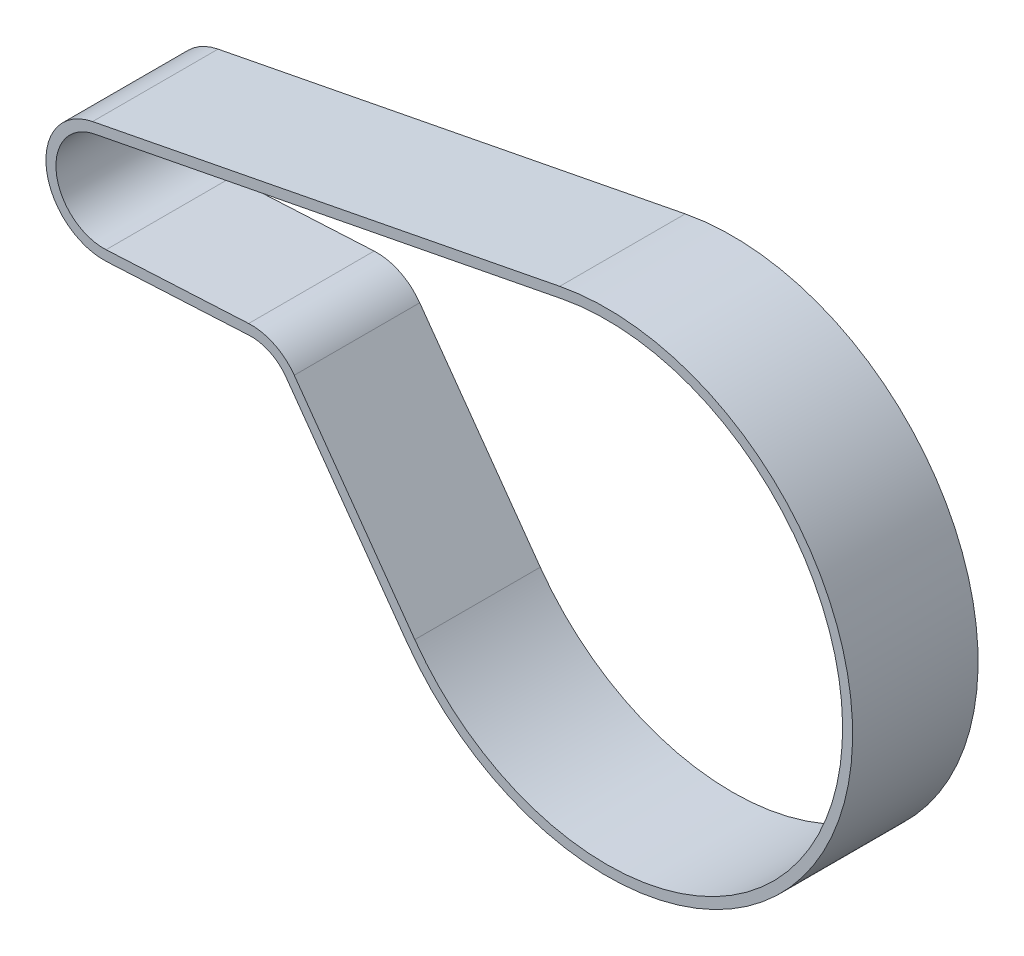
from build123d import *

# Parameters (mm, degrees)
EXTRUDE_THIN1_DEPTH      = 15.5
EXTRUDE_THIN1_DEPTH_BACK = 9.5


with BuildPart() as part:
    # Sketch2 → Extrude-Thin1 (new, two sides)
    with BuildSketch(Plane.XY) as extrude_thin1_sk:
        with BuildLine():
            Line((29.005065407, -10.011404827), (0.595527741, -11.48456994))
            ThreePointArc((0.595527741, -11.48456994), (-11.414556502, -1.399249751), (-2.196085326, 11.288366101))
            Line((-2.196085326, 11.288366101), (90.892766873, 29.398255563))
            ThreePointArc((90.892766873, 29.398255563), (145.769058071, -36.838780342), (60.377030306, -47.180630045))
            Line((60.377030306, -47.180630045), (36.361977726, -13.559482543))
            ThreePointArc((36.361977726, -13.559482543), (33.137621296, -10.843871329), (29.005065407, -10.011404827))
        make_face()
        with BuildLine():
            Line((28.901495366, -8.014088315), (0.491957699, -9.487253429))
            ThreePointArc((0.491957699, -9.487253429), (-9.429416241, -1.155901968), (-1.814157443, 9.325171997))
            Line((-1.814157443, 9.325171997), (91.274694756, 27.435061458))
            ThreePointArc((91.274694756, 27.435061458), (143.911137334, -36.098421961), (62.004498457, -46.01815535))
            Line((62.004498457, -46.01815535), (37.989445877, -12.397007847))
            ThreePointArc((37.989445877, -12.397007847), (34.006417346, -9.042429289), (28.901495366, -8.014088315))
        make_face(mode=Mode.SUBTRACT)
    extrude(amount=EXTRUDE_THIN1_DEPTH)
    extrude(extrude_thin1_sk.sketch, amount=-EXTRUDE_THIN1_DEPTH_BACK)


solid = part.part
